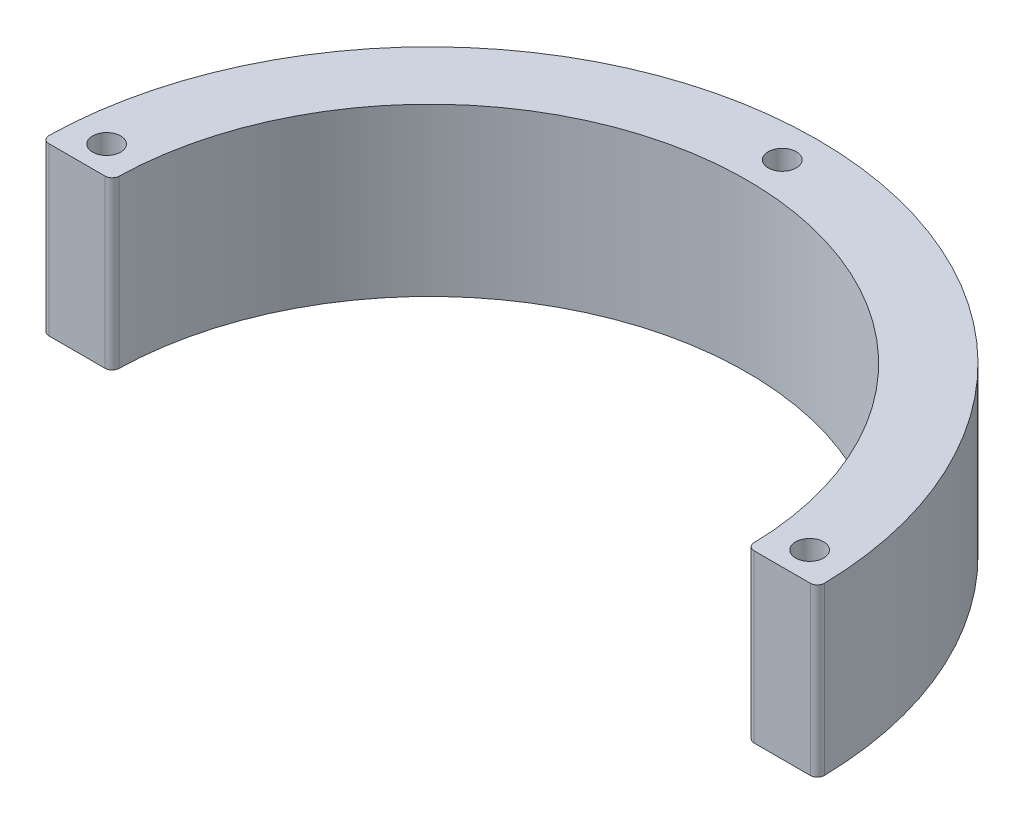
from build123d import *

# Parameters (mm, degrees)
EXTRUDE_1_DEPTH     = 11.85
SKETCH_2_R          = 1
CUT_EXTRUDE_1_DEPTH = 12.85
FILLET_1_R          = 0.5


with BuildPart() as part:
    # 草图1 → 凸台-拉伸1 (new body)
    with BuildSketch(Plane(origin=(0, 0, 0), x_dir=(1, 0, 0), z_dir=(0, 1, 0))):
        with BuildLine():
            Line((-27.6, 0), (-22.6, 0))
            ThreePointArc((-22.6, 0), (0, 22.6), (22.6, 0))
            Line((22.6, 0), (27.6, 0))
            ThreePointArc((27.6, 0), (0, 27.6), (-27.6, 0))
        make_face()
    extrude(amount=EXTRUDE_1_DEPTH)

    # 草图2 → 切除-拉伸1 (cut, through all)
    with BuildSketch(Plane(origin=(0, 11.85, 0), x_dir=(1, 0, 0), z_dir=(0, 1, 0))):
        with Locations((-25.017738418, 2.03045917)):
            Circle(SKETCH_2_R)
        with Locations((25.017738418, 2.03045917)):
            Circle(SKETCH_2_R)
        with Locations((0, 25.1)):
            Circle(SKETCH_2_R)
    extrude(amount=-CUT_EXTRUDE_1_DEPTH, mode=Mode.SUBTRACT)

    # 圆角1
    fillet_1_edges = [part.edges().sort_by_distance(p)[0] for p in [
        (-22.6, 5.925, 0),
        (-27.6, 5.925, 0),
        (27.6, 5.925, 0),
        (22.6, 5.925, 0),
    ]]
    fillet(fillet_1_edges, radius=FILLET_1_R)


solid = part.part
